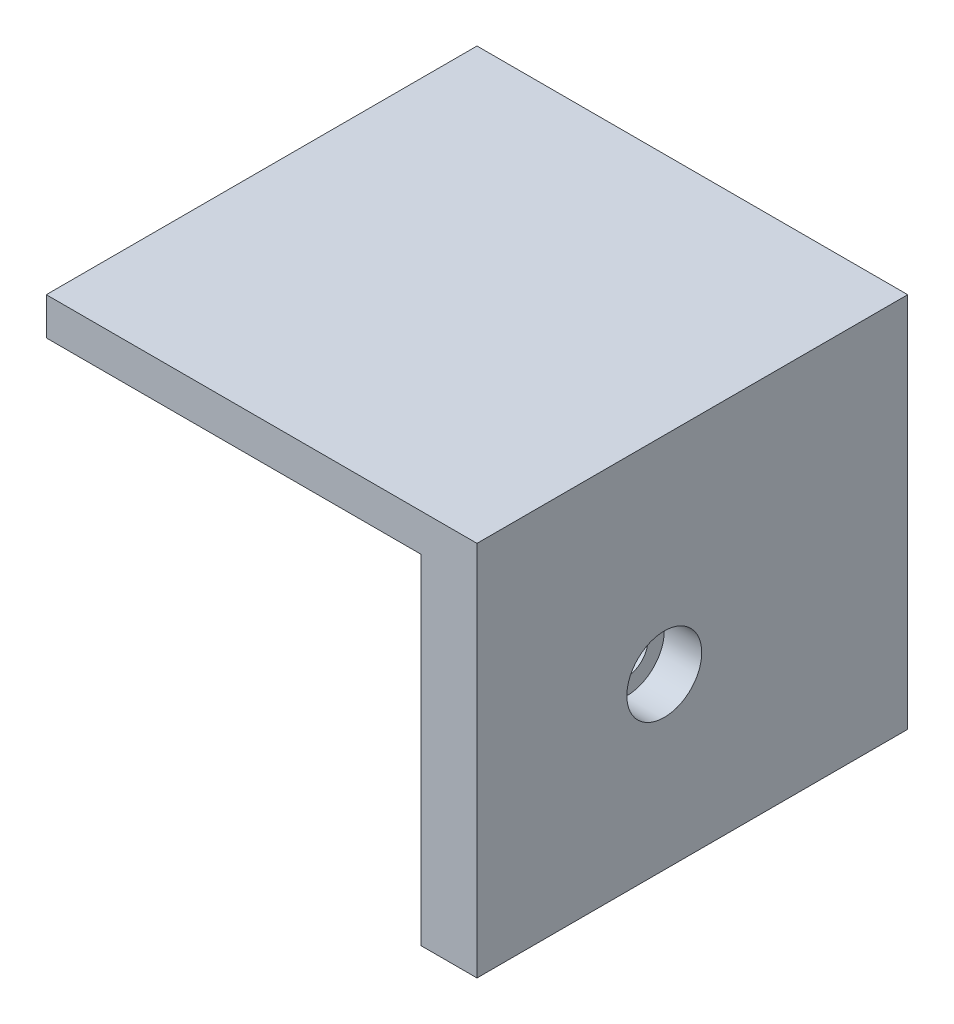
from build123d import *

# Parameters (mm, degrees)
EXTRUDE_THIN1_DEPTH                      = 36.2
SKETCH2_W                                = 46
SKETCH2_H                                = 46
BOSS_EXTRUDE1_DEPTH                      = 4
CBORE_FOR_M4_SHCS1_D                     = 4.5
CBORE_FOR_M4_SHCS1_DEPTH                 = 6
CBORE_FOR_M4_SHCS1_CBORE_D               = 8
CBORE_FOR_M4_SHCS1_CBORE_DEPTH           = 4
CBORE_FOR_M4_SHCS1_ON_FACE_2_D           = 4.5
CBORE_FOR_M4_SHCS1_ON_FACE_2_DEPTH       = 6
CBORE_FOR_M4_SHCS1_ON_FACE_2_CBORE_D     = 8
CBORE_FOR_M4_SHCS1_ON_FACE_2_CBORE_DEPTH = 4


with BuildPart() as part:
    # Sketch1 → Extrude-Thin1 (new body)
    with BuildSketch(Plane(origin=(0, 0, 0), x_dir=(1, 0, 0), z_dir=(0, 1, 0))):
        Polygon((-40, 0), (0, 0), (0, -40), (6, -40), (6, 6), (-40, 6), align=None)
    extrude(amount=EXTRUDE_THIN1_DEPTH)

    # Sketch2 → Boss-Extrude1 (add)
    with BuildSketch(Plane(origin=(0, 36.2, 0), x_dir=(1, 0, 0), z_dir=(0, 1, 0))):
        with Locations((-17, -17)):
            Rectangle(SKETCH2_W, SKETCH2_H)
    extrude(amount=BOSS_EXTRUDE1_DEPTH)

    # CBORE for M4 SHCS1
    with Locations(Plane(origin=(6, 18.1, 20), x_dir=(0, 0, 1), z_dir=(1, 0, 0))):
        with Locations((0, 0)):
            CounterBoreHole(CBORE_FOR_M4_SHCS1_D / 2, CBORE_FOR_M4_SHCS1_CBORE_D / 2, CBORE_FOR_M4_SHCS1_CBORE_DEPTH, depth=CBORE_FOR_M4_SHCS1_DEPTH)

    # CBORE for M4 SHCS1 on face 2
    with Locations(Plane(origin=(-20, 18.1, -6), x_dir=(-1, 0, 0), z_dir=(0, 0, -1))):
        with Locations((0, 0)):
            CounterBoreHole(CBORE_FOR_M4_SHCS1_ON_FACE_2_D / 2, CBORE_FOR_M4_SHCS1_ON_FACE_2_CBORE_D / 2, CBORE_FOR_M4_SHCS1_ON_FACE_2_CBORE_DEPTH, depth=CBORE_FOR_M4_SHCS1_ON_FACE_2_DEPTH)


solid = part.part
